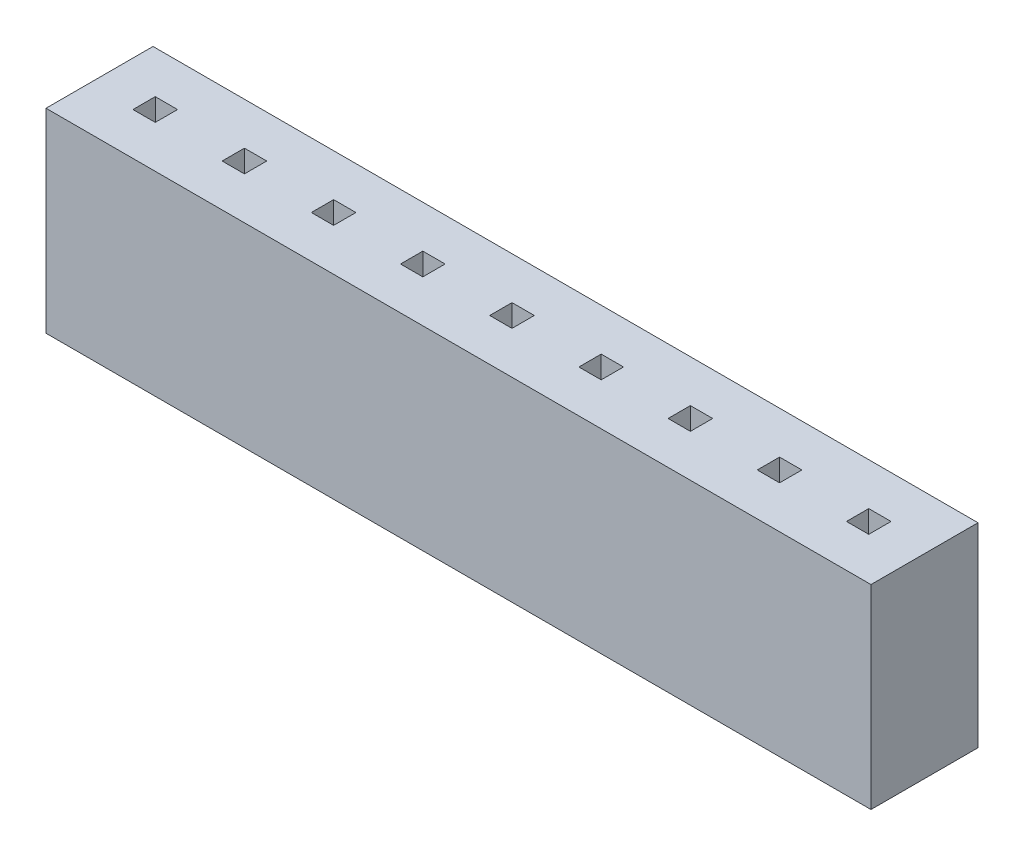
from build123d import *

# Parameters (mm, degrees)
SKETCH1_W           = 18.5
SKETCH1_H           = 2.4
BOSS_EXTRUDE1_DEPTH = 4.37
SKETCH2_W           = 0.5
SKETCH2_H           = 0.5
CUT_EXTRUDE1_DEPTH  = 4.37


with BuildPart() as part:
    # Sketch1 → Boss-Extrude1 (new body)
    with BuildSketch(Plane(origin=(0, 0, 0), x_dir=(1, 0, 0), z_dir=(0, 1, 0))):
        with Locations((9, 1)):
            Rectangle(SKETCH1_W, SKETCH1_H)
    extrude(amount=BOSS_EXTRUDE1_DEPTH)

    # Sketch2 → Cut-Extrude1 (cut)
    with BuildSketch(Plane(origin=(0, 4.37, 0), x_dir=(1, 0, 0), z_dir=(0, 1, 0))):
        with Locations((3, 1)):
            Rectangle(SKETCH2_W, SKETCH2_H)
        with Locations((1, 1)):
            Rectangle(SKETCH2_W, SKETCH2_H)
        with Locations((5, 1)):
            Rectangle(SKETCH2_W, SKETCH2_H)
        with Locations((7, 1)):
            Rectangle(SKETCH2_W, SKETCH2_H)
        with Locations((9, 1)):
            Rectangle(SKETCH2_W, SKETCH2_H)
        with Locations((11, 1)):
            Rectangle(SKETCH2_W, SKETCH2_H)
        with Locations((13, 1)):
            Rectangle(SKETCH2_W, SKETCH2_H)
        with Locations((15, 1)):
            Rectangle(SKETCH2_W, SKETCH2_H)
        with Locations((17, 1)):
            Rectangle(SKETCH2_W, SKETCH2_H)
    extrude(amount=-CUT_EXTRUDE1_DEPTH, mode=Mode.SUBTRACT)


solid = part.part
